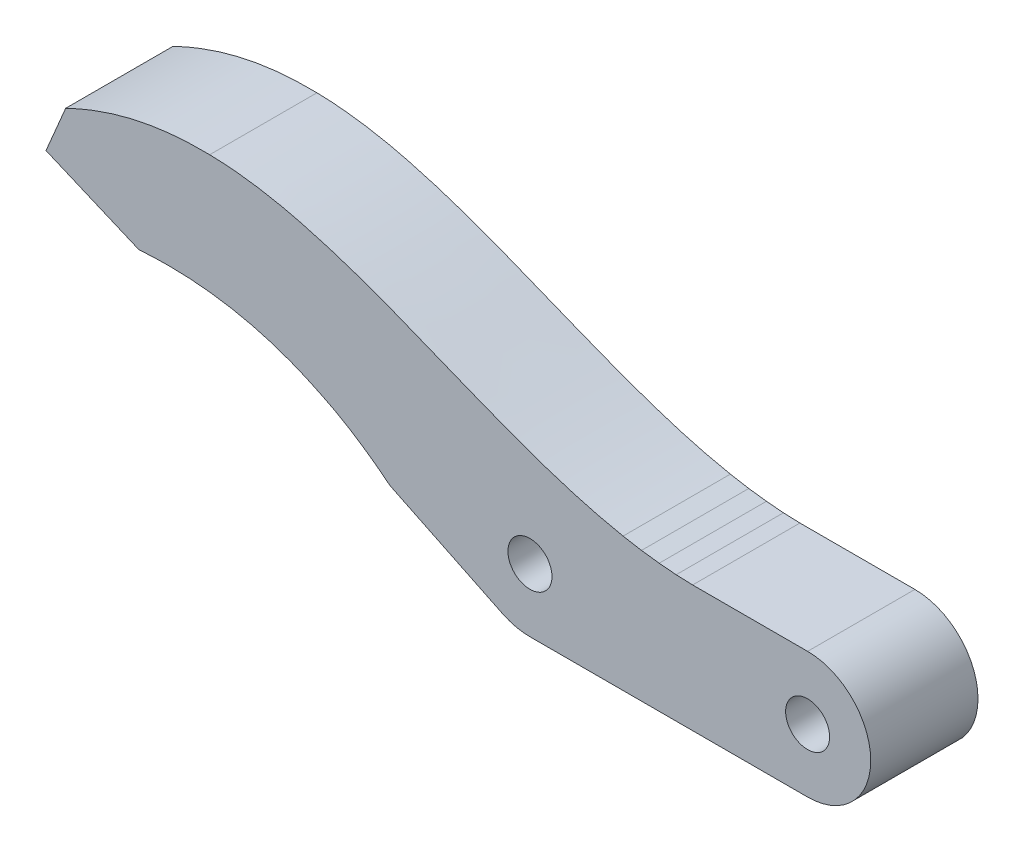
from build123d import *

# Parameters (mm, degrees)
CROQUIS1_R              = 1.743
CROQUIS1_R_2            = 1.745
SALIENTE_EXTRUIR1_DEPTH = 8.5


with BuildPart() as part:
    # Croquis1 → Saliente-Extruir1 (new body)
    with BuildSketch(Plane.XY):
        with BuildLine():
            Line((-8.694, 5), (0, 5))
            ThreePointArc((0, 5), (5, 0), (0, -5))
            Line((0, -5), (-22, -5))
            add(Edge.make_bspline(
                [(-22, -5), (-22.376114087, -5.000730995), (-23.127936381, -4.912027071), (-23.842743751, -4.662668406), (-24.18108985, -4.497)],
                knots=[0, 0, 0, 0, 0.499595813, 1, 1, 1, 1], degree=3))
            Line((-24.18108985, -4.497), (-33.082774185, -0.176))
            Line((-33.082774185, -0.176), (-34.150774185, 0.655))
            Line((-34.150774185, 0.655), (-35.235774185, 1.426))
            Line((-35.235774185, 1.426), (-36.329774185, 2.134))
            Line((-36.329774185, 2.134), (-37.433774185, 2.78))
            Line((-37.433774185, 2.78), (-38.592774185, 3.367))
            add(Edge.make_bspline(
                [(-38.592774185, 3.367), (-39.332541124, 3.73458873), (-40.463584029, 4.233674803), (-42.009779682, 4.789621338), (-43.18029785, 5.1503195), (-44.367367964, 5.455509833), (-45.571550782, 5.707001476), (-46.794958977, 5.902822636), (-48.465017773, 6.09379478), (-49.733307298, 6.151003132), (-50.584774185, 6.154)],
                knots=[0, 0, 0, 0, 0.199499465, 0.298230174, 0.396705181, 0.49521602, 0.594152289, 0.693710503, 0.79435234, 1, 1, 1, 1], degree=3))
            add(Edge.make_bspline(
                [(-50.584774185, 6.154), (-51.784512946, 6.156123129), (-52.980774185, 6.067)],
                knots=[0, 0, 0, 1, 1, 1], degree=2))
            Line((-52.980774185, 6.067), (-60.345774185, 9.189))
            Line((-60.345774185, 9.189), (-58.785774185, 12.872))
            add(Edge.make_bspline(
                [(-47.376936723, 15.389), (-48.196892042, 15.403291142), (-49.398277121, 15.379717661), (-50.970775635, 15.224558885), (-52.098811061, 15.061295448), (-53.219989961, 14.84128524), (-54.336112455, 14.567008142), (-55.4494326, 14.235014339), (-56.95056509, 13.707761437), (-58.056017514, 13.22696924), (-58.785774185, 12.872)],
                knots=[0, 0, 0, 0, 0.208580678, 0.30512865, 0.401665607, 0.498317749, 0.595560953, 0.693826211, 0.793634588, 1, 1, 1, 1], degree=3))
            add(Edge.make_bspline(
                [(-14.621, 5.599), (-15.563222131, 5.781119084), (-17.011007703, 6.120848832), (-18.989445264, 6.684731463), (-20.635507849, 7.208092626), (-22.439927245, 7.83467175), (-24.540120329, 8.619913648), (-27.091397312, 9.631396334), (-29.90077475, 10.772491334), (-32.584990491, 11.839895748), (-34.794603661, 12.665403671), (-36.602182307, 13.292835375), (-38.193000796, 13.796531357), (-39.671884667, 14.211722291), (-41.068328907, 14.576337495), (-42.402463198, 14.85165039), (-43.69443221, 15.078308418), (-45.342048595, 15.292337563), (-46.568508645, 15.371828774), (-47.376936723, 15.389)],
                knots=[0, 0, 0, 0, 0.083834458, 0.129855591, 0.179713331, 0.234726598, 0.296726991, 0.375600314, 0.474504455, 0.561662864, 0.627975282, 0.680575135, 0.728822097, 0.773739203, 0.814774439, 0.854888969, 0.892720603, 0.929358167, 1, 1, 1, 1], degree=3))
            Line((-14.621, 5.599), (-13.161, 5.346))
            Line((-13.161, 5.346), (-11.763, 5.166))
            Line((-11.763, 5.166), (-10.416, 5.05))
            Line((-10.416, 5.05), (-9.11, 5))
            Line((-9.11, 5), (-8.694, 5))
        make_face()
        Circle(CROQUIS1_R, mode=Mode.SUBTRACT)
        with Locations((-22, 0)):
            Circle(CROQUIS1_R_2, mode=Mode.SUBTRACT)
    extrude(amount=SALIENTE_EXTRUIR1_DEPTH)


solid = part.part
